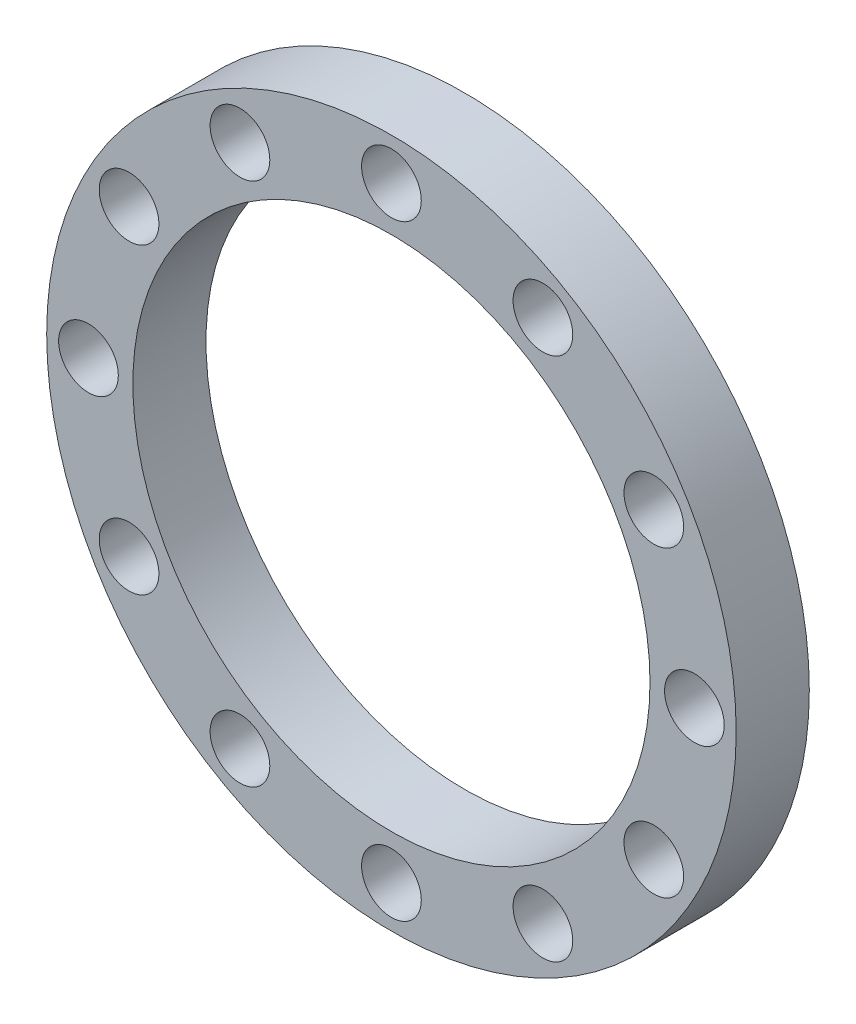
from build123d import *

# Parameters (mm, degrees)
SKETCH1_R           = 330
SKETCH1_R_2         = 247.5
BOSS_EXTRUDE1_DEPTH = 70
SKETCH2_R           = 28.575
CUT_EXTRUDE1_DEPTH  = 131


with BuildPart() as part:
    # Sketch1 → Boss-Extrude1 (new body)
    with BuildSketch(Plane.XY):
        Circle(SKETCH1_R)
        Circle(SKETCH1_R_2, mode=Mode.SUBTRACT)
    extrude(amount=BOSS_EXTRUDE1_DEPTH)

    # Sketch2 → Cut-Extrude1 (cut)
    with BuildSketch(Plane.XY):
        with Locations((0, 290)):
            Circle(SKETCH2_R)
        with Locations((145, 251.147367097)):
            Circle(SKETCH2_R)
        with Locations((251.147367097, 145)):
            Circle(SKETCH2_R)
        with Locations((290, 0)):
            Circle(SKETCH2_R)
        with Locations((251.147367098, -145)):
            Circle(SKETCH2_R)
        with Locations((145, -251.147367097)):
            Circle(SKETCH2_R)
        with Locations((0, -290)):
            Circle(SKETCH2_R)
        with Locations((-145, -251.147367097)):
            Circle(SKETCH2_R)
        with Locations((-251.147367097, -145)):
            Circle(SKETCH2_R)
        with Locations((-290, 0)):
            Circle(SKETCH2_R)
        with Locations((-251.147367097, 145)):
            Circle(SKETCH2_R)
        with Locations((-145, 251.147367097)):
            Circle(SKETCH2_R)
    extrude(amount=CUT_EXTRUDE1_DEPTH, mode=Mode.SUBTRACT)


solid = part.part
